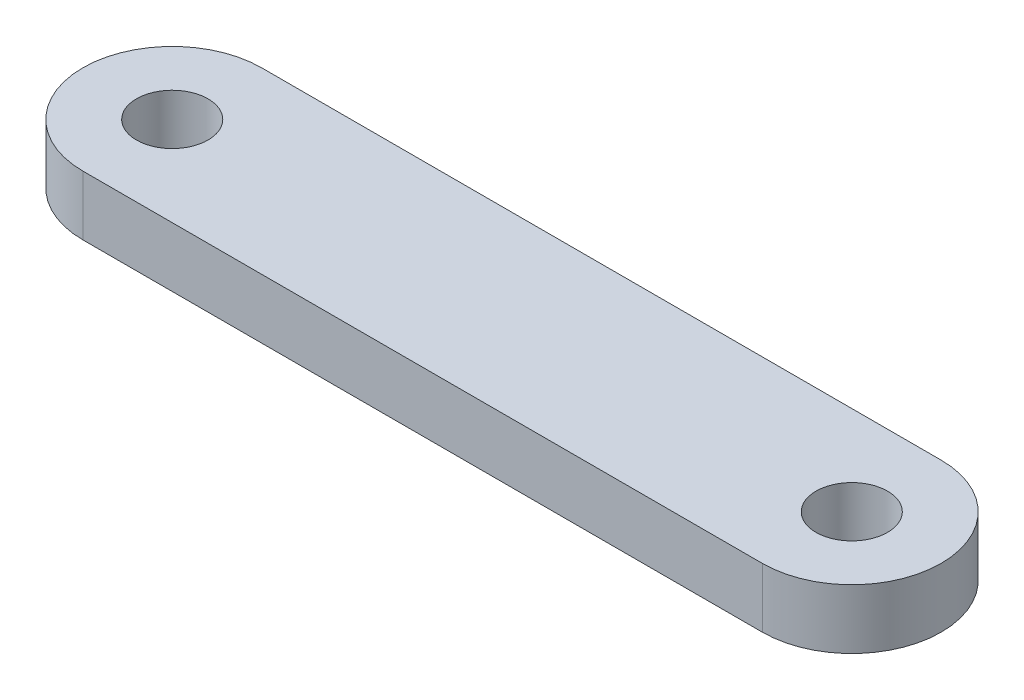
from build123d import *

# Parameters (mm, degrees)
SKETCH1_R           = 3
BOSS_EXTRUDE1_DEPTH = 5


with BuildPart() as part:
    # Sketch1 → Boss-Extrude1 (new body)
    with BuildSketch(Plane(origin=(0, 0, 0), x_dir=(1, 0, 0), z_dir=(0, 1, 0))):
        with BuildLine():
            Line((0, 7.5), (57, 7.5))
            ThreePointArc((57, 7.5), (64.5, 0), (57, -7.5))
            Line((57, -7.5), (0, -7.5))
            ThreePointArc((0, -7.5), (-7.5, 0), (0, 7.5))
        make_face()
        with Locations((57, 0)):
            Circle(SKETCH1_R, mode=Mode.SUBTRACT)
        Circle(SKETCH1_R, mode=Mode.SUBTRACT)
    extrude(amount=BOSS_EXTRUDE1_DEPTH)


solid = part.part
